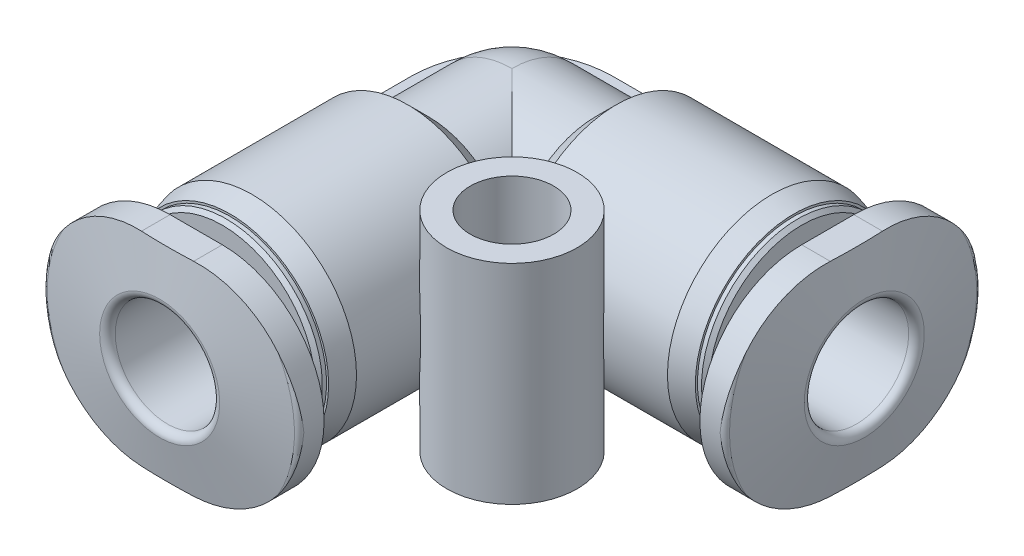
from build123d import *

# Parameters (mm, degrees)
SCHNITT_LINEAR_AUSTRAGEN1_DEPTH      = 1.4
AUFSATZ_LINEAR_AUSTRAGEN1_DEPTH      = 4
AUFSATZ_LINEAR_AUSTRAGEN2_DEPTH      = 4
SCHNITT_LINEAR_AUSTRAGEN2_DEPTH      = 1.4
SKIZZE9_R                            = 2.5
AUFSATZ_LINEAR_AUSTRAGEN3_DEPTH      = 4
AUFSATZ_LINEAR_AUSTRAGEN3_DEPTH_BACK = 4
BOHRUNG1_D                           = 3.2
BOHRUNG1_DEPTH                       = 9
ROTATION3_ANGLE                      = 90


with BuildPart() as part:
    # Skizze1 → Rotation1 (revolve)
    with BuildSketch(Plane.XY):
        with BuildLine():
            Line((0, 3.2), (3.2, 3.2))
            Line((3.2, 3.2), (4, 4))
            Line((4, 4), (9.957142857, 4))
            Line((9.957142857, 4), (10.8, 3.774157109))
            Line((10.8, 3.774157109), (10.8, 3.693772352))
            Line((10.8, 3.693772352), (10.958578644, 3.693772352))
            Line((10.958578644, 3.693772352), (11.1, 3.552350995))
            Line((11.1, 3.552350995), (11.1, 2.7))
            Line((11.1, 2.7), (11.73, 2.7))
            ThreePointArc((11.73, 2.7), (11.991629509, 2.808370491), (12.1, 3.07))
            Line((12.1, 3.07), (12.1, 4.9))
            Line((12.1, 4.9), (12.873729924, 4.9))
            ThreePointArc((12.873729924, 4.9), (13.002287446, 4.853208889), (13.070691475, 4.734729636))
            Line((13.070691475, 4.734729636), (13.5, 2.3))
            Line((13.5, 2.3), (13.5, 0))
            Line((13.5, 0), (-3.2, 0))
            ThreePointArc((-3.2, 0), (-2.2627417, 2.2627417), (0, 3.2))
        make_face()
    revolve(axis=Axis((13.5, 0, 0), (-1, 0, 0)))

    # Skizze2 → Schnitt-Linear austragen1 (cut)
    with BuildSketch(Plane(origin=(13.5, 0, 0), x_dir=(0, 0, -1), z_dir=(1, 0, 0))):
        Polygon((-5.88, -3.394819583), (0, -6.789639166), (5.88, -3.394819583), (5.88, 3.394819583), (0, 6.789639166), (-5.88, 3.394819583), align=None)
        with BuildLine():
            Line((-1, -3.9), (1, -3.9))
            ThreePointArc((1, -3.9), (3.757716447, -2.757716447), (4.9, 0))
            ThreePointArc((4.9, 0), (3.757716447, 2.757716447), (1, 3.9))
            Line((1, 3.9), (-1, 3.9))
            ThreePointArc((-1, 3.9), (-3.757716447, 2.757716447), (-4.9, 0))
            ThreePointArc((-4.9, 0), (-3.757716447, -2.757716447), (-1, -3.9))
        make_face(mode=Mode.SUBTRACT)
    extrude(amount=-SCHNITT_LINEAR_AUSTRAGEN1_DEPTH, mode=Mode.SUBTRACT)

    # Skizze3 → Aufsatz-Linear austragen1 (add)
    with BuildSketch(Plane(origin=(0, 0, 0), x_dir=(0, 0, -1), z_dir=(1, 0, 0))):
        with BuildLine():
            Line((-3.872983346, -1), (3.872983346, -1))
            ThreePointArc((3.872983346, -1), (4, 0), (3.872983346, 1))
            Line((3.872983346, 1), (-3.872983346, 1))
            ThreePointArc((-3.872983346, 1), (-4, 0), (-3.872983346, -1))
        make_face()
    extrude(amount=AUFSATZ_LINEAR_AUSTRAGEN1_DEPTH)

    # Skizze5 → Aufsatz-Linear austragen2 (add)
    with BuildSketch(Plane.XY):
        with BuildLine():
            Line((-3.872983346, -1), (0, -1))
            Line((0, -1), (0, 1))
            Line((0, 1), (-3.872983346, 1))
            ThreePointArc((-3.872983346, 1), (-4, 0), (-3.872983346, -1))
        make_face()
    extrude(amount=AUFSATZ_LINEAR_AUSTRAGEN2_DEPTH)

    # Skizze6 → Rotation2 (revolve)
    with BuildSketch(Plane(origin=(0, 0, 0), x_dir=(0, 0, -1), z_dir=(1, 0, 0))):
        with BuildLine():
            Line((0, 0), (0, -3.2))
            Line((0, -3.2), (-3.2, -3.2))
            Line((-3.2, -3.2), (-4, -4))
            Line((-4, -4), (-9.957142857, -4))
            Line((-9.957142857, -4), (-10.8, -3.774157109))
            Line((-10.8, -3.774157109), (-10.8, -3.693772352))
            Line((-10.8, -3.693772352), (-10.958578644, -3.693772352))
            Line((-10.958578644, -3.693772352), (-11.1, -3.552350995))
            Line((-11.1, -3.552350995), (-11.1, -2.7))
            Line((-11.1, -2.7), (-11.73, -2.7))
            ThreePointArc((-11.73, -2.7), (-11.991629509, -2.808370491), (-12.1, -3.07))
            Line((-12.1, -3.07), (-12.1, -4.9))
            Line((-12.1, -4.9), (-12.873729924, -4.9))
            ThreePointArc((-12.873729924, -4.9), (-13.002287446, -4.853208889), (-13.070691475, -4.734729636))
            Line((-13.070691475, -4.734729636), (-13.5, -2.3))
            Line((-13.5, -2.3), (-13.5, 0))
            Line((-13.5, 0), (0, 0))
        make_face()
    revolve(axis=Axis((0, 0, 13.5), (0, 0, -1)))

    # Skizze7 → Schnitt-Linear austragen2 (cut)
    with BuildSketch(Plane.XY.offset(13.5)):
        Polygon((-5.88, -3.394819583), (0, -6.789639166), (5.88, -3.394819583), (5.88, 3.394819583), (0, 6.789639166), (-5.88, 3.394819583), align=None)
        with BuildLine():
            Line((-1, -3.9), (1, -3.9))
            ThreePointArc((1, -3.9), (3.757716447, -2.757716447), (4.9, 0))
            ThreePointArc((4.9, 0), (3.757716447, 2.757716447), (1, 3.9))
            Line((1, 3.9), (-1, 3.9))
            ThreePointArc((-1, 3.9), (-3.757716447, 2.757716447), (-4.9, 0))
            ThreePointArc((-4.9, 0), (-3.757716447, -2.757716447), (-1, -3.9))
        make_face(mode=Mode.SUBTRACT)
    extrude(amount=-SCHNITT_LINEAR_AUSTRAGEN2_DEPTH, mode=Mode.SUBTRACT)

    # Skizze9 → Aufsatz-Linear austragen3 (add, two sides)
    with BuildSketch(Plane(origin=(0, 0, 0), x_dir=(1, 0, 0), z_dir=(0, 1, 0))) as aufsatz_linear_austragen3_sk:
        with Locations((5.5, -5.5)):
            Circle(SKIZZE9_R)
    extrude(amount=AUFSATZ_LINEAR_AUSTRAGEN3_DEPTH)
    extrude(aufsatz_linear_austragen3_sk.sketch, amount=-AUFSATZ_LINEAR_AUSTRAGEN3_DEPTH_BACK)

    # Bohrung1
    with Locations(Plane(origin=(0, 4, 0), x_dir=(1, 0, 0), z_dir=(0, 1, 0))):
        with Locations((5.5, -5.5)):
            Hole(BOHRUNG1_D / 2, depth=BOHRUNG1_DEPTH)

    # Skizze12 → Rotation3 (revolve)
    with BuildSketch(Plane(origin=(0, 0, 0), x_dir=(0, 0, -1), z_dir=(1, 0, 0))):
        with BuildLine():
            Line((0, 1), (3.872983346, 1))
            ThreePointArc((3.872983346, 1), (4, 0), (3.872983346, -1))
            Line((3.872983346, -1), (0, -1))
            Line((0, -1), (0, 1))
        make_face()
    revolve(axis=Axis((0, -1, 0), (0, 1, 0)), revolution_arc=ROTATION3_ANGLE)

    # Skizze8 → Schnitt-Rotation1 (revolve, cut)
    with BuildSketch(Plane(origin=(0, 0, 0), x_dir=(0, 0, -1), z_dir=(1, 0, 0))):
        with BuildLine():
            Line((0, 0), (0, -1.5))
            Line((0, -1.5), (-2, -1.5))
            Line((-2, -1.5), (-2, -1.8))
            ThreePointArc((-2, -1.8), (-2.058578644, -1.941421356), (-2.2, -2))
            Line((-2.2, -2), (-13.2, -2))
            ThreePointArc((-13.2, -2), (-13.412132034, -2.087867966), (-13.5, -2.3))
            Line((-13.5, -2.3), (-13.5, 0))
            Line((-13.5, 0), (0, 0))
        make_face()
    revolve(axis=Axis((0, 0, 13.5), (0, 0, -1)), mode=Mode.SUBTRACT)

    # Skizze4 → Schnitt-Rotation2 (revolve, cut)
    with BuildSketch(Plane(origin=(0, 0, 0), x_dir=(1, 0, 0), z_dir=(0, 1, 0))):
        with BuildLine():
            Line((0, 1.5), (2, 1.5))
            Line((2, 1.5), (2, 1.8))
            ThreePointArc((2, 1.8), (2.058578644, 1.941421356), (2.2, 2))
            Line((2.2, 2), (13.2, 2))
            ThreePointArc((13.2, 2), (13.412132034, 2.087867966), (13.5, 2.3))
            Line((13.5, 2.3), (13.5, 0))
            Line((13.5, 0), (-1.5, 0))
            ThreePointArc((-1.5, 0), (-1.060660172, 1.060660172), (0, 1.5))
        make_face()
    revolve(axis=Axis((13.5, 0, 0), (-1, 0, 0)), mode=Mode.SUBTRACT)


solid = part.part
